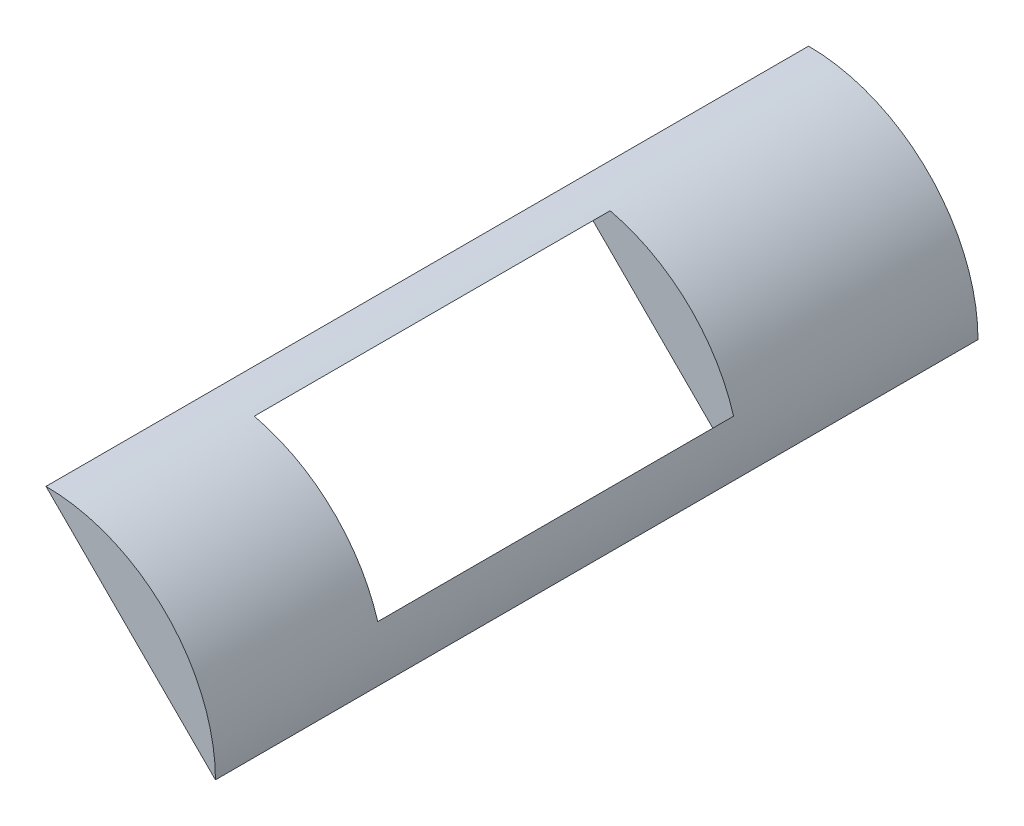
from build123d import *

# Parameters (mm, degrees)
DODANIE_WYCI_GNI_CIE1_DEPTH = 45
WYTNIJ_WYCI_GNI_CIE1_DEPTH  = 60
SZKIC4_W                    = 21
SZKIC4_H                    = 10
WYTNIJ_WYCI_GNI_CIE2_DEPTH  = 60


with BuildPart() as part:
    # Szkic1 → Dodanie-wyciągnięcie1 (new body)
    with BuildSketch(Plane.XY):
        with BuildLine():
            Line((0, 0), (0, 10))
            ThreePointArc((0, 10), (7.071067812, 7.071067812), (10, 0))
            Line((10, 0), (0, 0))
        make_face()
    extrude(amount=DODANIE_WYCI_GNI_CIE1_DEPTH)

    # Szkic2 → Wytnij-wyciągnięcie1 (cut)
    with BuildSketch(Plane.XY.offset(45)):
        Polygon((0, 10), (10, 0), (0, 0), align=None)
    extrude(amount=-WYTNIJ_WYCI_GNI_CIE1_DEPTH, mode=Mode.SUBTRACT)

    # Szkic4 → Wytnij-wyciągnięcie2 (cut)
    with BuildSketch(Plane(origin=(5, 5, 0), x_dir=(0, 0, 1), z_dir=(-0.707106781, -0.707106781, 0))):
        with Locations((24.5, 0.262214186)):
            Rectangle(SZKIC4_W, SZKIC4_H)
    extrude(amount=-WYTNIJ_WYCI_GNI_CIE2_DEPTH, mode=Mode.SUBTRACT)


solid = part.part
